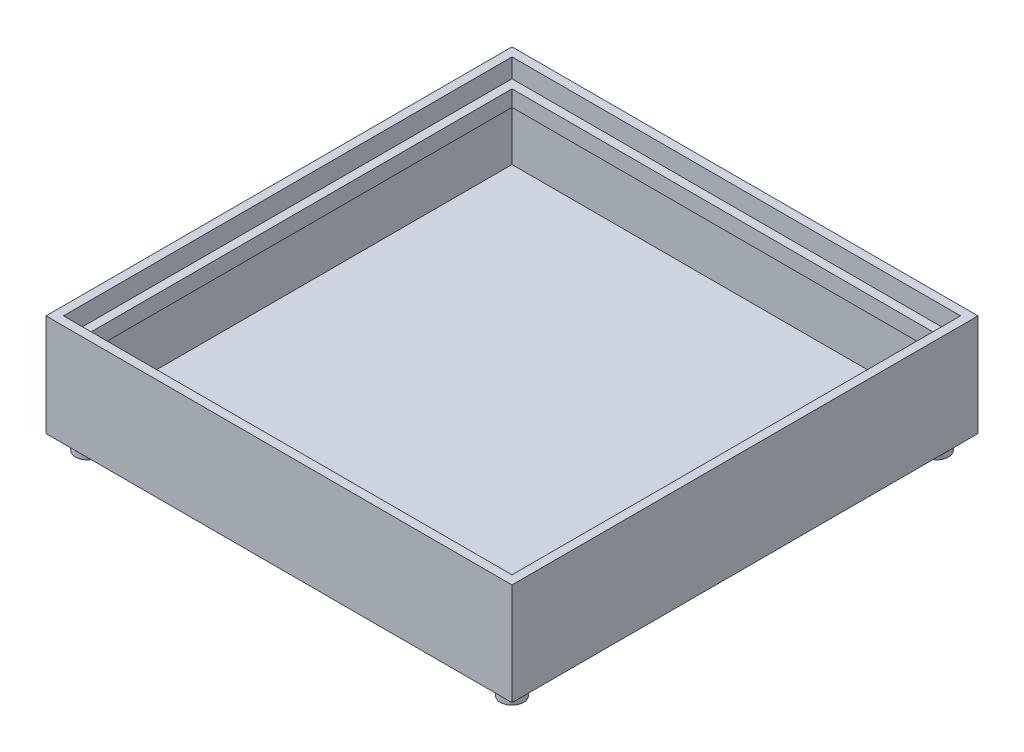
from build123d import *

# Parameters (mm, degrees)
SKETCH2_W                                  = 160
SKETCH2_H                                  = 160
OUTER_BLOCK_DEPTH                          = 35
SKETCH12_W                                 = 154
SKETCH12_H                                 = 154
CUT_EXTRUDE1_DEPTH                         = 6.5
SKETCH14_W                                 = 154
SKETCH14_H                                 = 154
CUT_EXTRUDE4_DEPTH                         = 20
SKETCH15_W                                 = 148
SKETCH15_H                                 = 148
CUT_EXTRUDE6_DEPTH                         = 7.5
SKETCH17_R                                 = 4
BOSS_EXTRUDE1_DEPTH                        = 5
MIRROR1_AT_THE_SECOND_PLANE_COPY_1_SKETC_R = 4
MIRROR1_AT_THE_SECOND_PLANE_COPY_1_DEPTH   = 5


with BuildPart() as part:
    # Sketch2 → Outer Block (new body)
    with BuildSketch(Plane(origin=(0, 0, 0), x_dir=(1, 0, 0), z_dir=(0, 1, 0))):
        Rectangle(SKETCH2_W, SKETCH2_H)
    extrude(amount=OUTER_BLOCK_DEPTH)

    # Sketch12 → Cut-Extrude1 (cut)
    with BuildSketch(Plane(origin=(0, 35, 0), x_dir=(1, 0, 0), z_dir=(0, 1, 0))):
        Rectangle(SKETCH12_W, SKETCH12_H)
    extrude(amount=-CUT_EXTRUDE1_DEPTH, mode=Mode.SUBTRACT)

    # Sketch14 → Cut-Extrude4 (cut)
    with BuildSketch(Plane(origin=(0, 3, 0), x_dir=(-1, 0, 0), z_dir=(0, -1, 0))):
        Rectangle(SKETCH14_W, SKETCH14_H)
    extrude(amount=-CUT_EXTRUDE4_DEPTH, mode=Mode.SUBTRACT)

    # Sketch15 → Cut-Extrude6 (cut)
    with BuildSketch(Plane(origin=(0, 28.5, 0), x_dir=(1, 0, 0), z_dir=(0, 1, 0))):
        Rectangle(SKETCH15_W, SKETCH15_H)
    extrude(amount=-CUT_EXTRUDE6_DEPTH, mode=Mode.SUBTRACT)

    # Sketch17 → Boss-Extrude1 (add)
    with BuildSketch(Plane.XZ):
        with Locations((-72.928932188, 72.928932188)):
            Circle(SKETCH17_R)
    boss_extrude1 = extrude(amount=BOSS_EXTRUDE1_DEPTH)

    # Mirror1: Boss-Extrude1 across plane
    add(boss_extrude1.mirror(Plane.XY))

    # Mirror1 at the second plane: Boss-Extrude1 across plane
    add(boss_extrude1.mirror(Plane(origin=(0, 0, 0), x_dir=(0, 0, 1), z_dir=(1, 0, 0))))

    # Mirror1 at the second plane copy 1 sketc → Mirror1 at the second plane copy 1 (add)
    with BuildSketch(Plane(origin=(0, 0, 0), x_dir=(-1, 0, 0), z_dir=(0, -1, 0))):
        with Locations((-72.928932188, 72.928932188)):
            Circle(MIRROR1_AT_THE_SECOND_PLANE_COPY_1_SKETC_R)
    extrude(amount=MIRROR1_AT_THE_SECOND_PLANE_COPY_1_DEPTH)


solid = part.part
